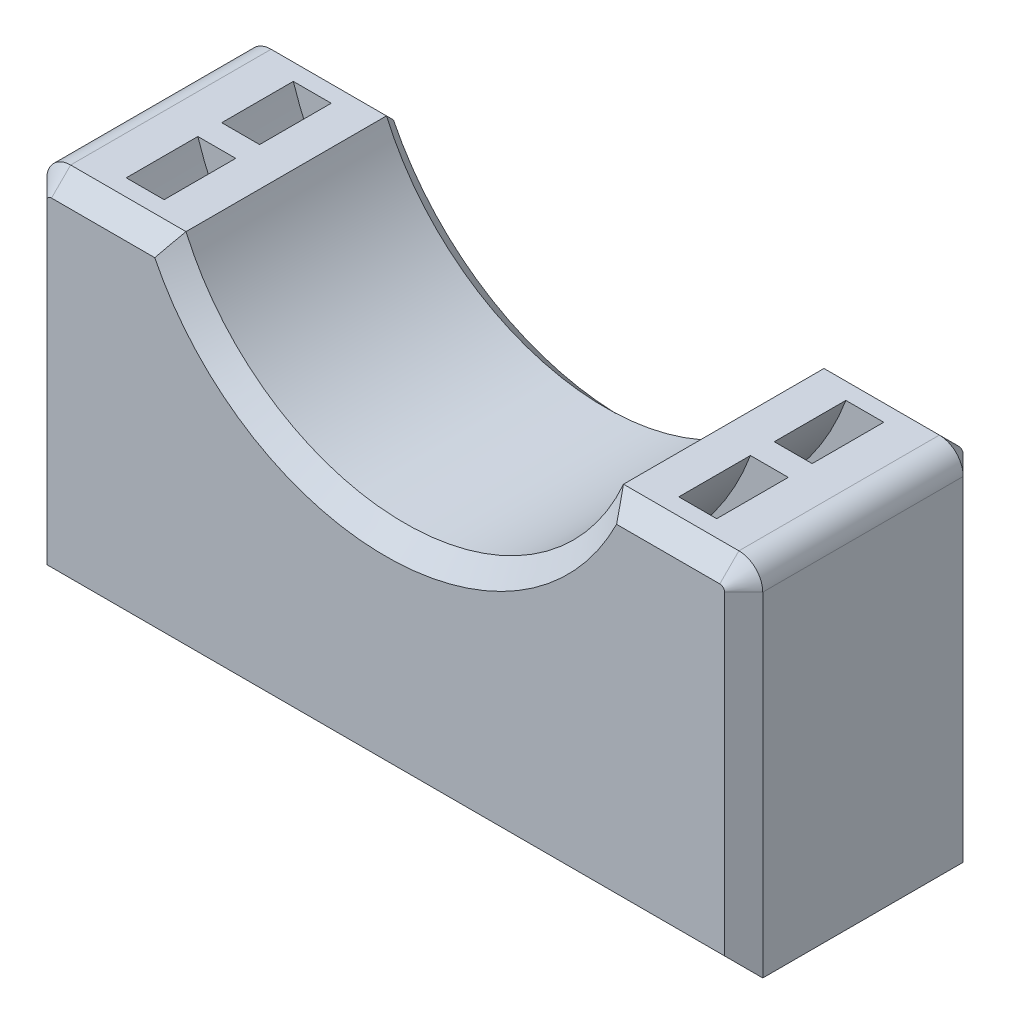
from build123d import *

# Parameters (mm, degrees)
BOSS_EXTRUDE1_DEPTH = 10
SKETCH2_R           = 1.4
CUT_EXTRUDE1_DEPTH  = 6
SKETCH3_W           = 3
SKETCH3_H           = 1.5
FILLET1_R           = 1
CHAMFER1_SIZE       = 0.8


with BuildPart() as part:
    # Sketch1 → Boss-Extrude1 (new body)
    with BuildSketch(Plane.XY):
        with BuildLine():
            Line((-15, 7.5), (-15, -7.5))
            Line((-15, -7.5), (15, -7.5))
            Line((15, -7.5), (15, 7.5))
            Line((15, 7.5), (9.16515139, 7.5))
            ThreePointArc((9.16515139, 7.5), (0, 1.5), (-9.16515139, 7.5))
            Line((-9.16515139, 7.5), (-15, 7.5))
        make_face()
    extrude(amount=BOSS_EXTRUDE1_DEPTH)

    # Sketch2 → Cut-Extrude1 (cut)
    with BuildSketch(Plane.XZ.offset(7.5)):
        with Locations((-8, 5)):
            Circle(SKETCH2_R)
        with Locations((8, 5)):
            Circle(SKETCH2_R)
    extrude(amount=-CUT_EXTRUDE1_DEPTH, mode=Mode.SUBTRACT)

    # Sketch3 → Cut-Revolve1 (revolve, cut)
    with BuildSketch(Plane(origin=(0, 0, 0), x_dir=(0, 0, -1), z_dir=(1, 0, 0))):
        with Locations((-7, -0.75)):
            Rectangle(SKETCH3_W, SKETCH3_H)
        with Locations((-3, -0.75)):
            Rectangle(SKETCH3_W, SKETCH3_H)
    revolve(axis=Axis((0, 11.5, 0), (0, 0, 1)), mode=Mode.SUBTRACT)

    # Fillet1
    fillet1_edges = [part.edges().sort_by_distance(p)[0] for p in [
        (15, 7.5, 5),
        (-15, 7.5, 5),
    ]]
    fillet(fillet1_edges, radius=FILLET1_R)

    # Chamfer1
    chamfer1_edges = [part.edges().sort_by_distance(p)[0] for p in [
        (0, 1.5, 0),
        (-15, -0.5, 10),
        (0, -7.5, 10),
        (15, -0.5, 10),
        (11.582575695, 7.5, 10),
        (-11.582575695, 7.5, 0),
        (-14.707106781, 7.207106781, 0),
        (14.707106781, 7.207106781, 0),
        (-11.582575695, 7.5, 10),
        (0, 1.5, 10),
        (-14.707106781, 7.207106781, 10),
        (14.707106781, 7.207106781, 10),
        (11.582575695, 7.5, 0),
        (15, -0.5, 0),
        (0, -7.5, 0),
        (-15, -0.5, 0),
    ]]
    chamfer(chamfer1_edges, length=CHAMFER1_SIZE)


solid = part.part
